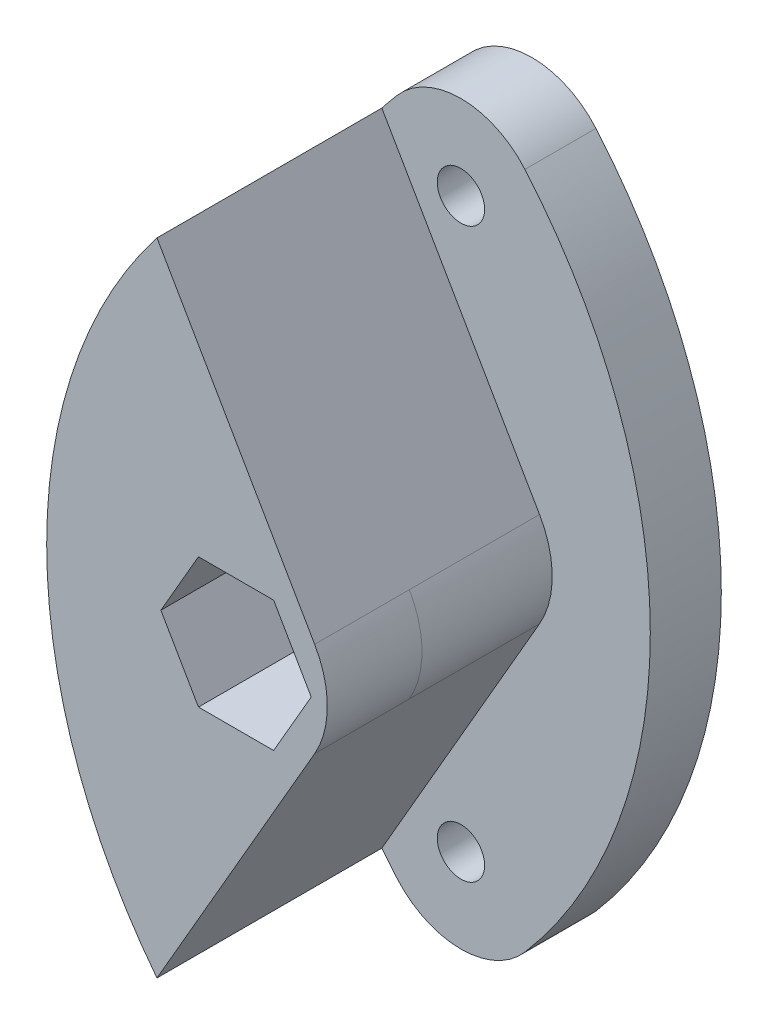
from build123d import *

# Parameters (mm, degrees)
AUFSATZ_LINEAR_AUSTRAGEN1_DEPTH                      = 5.5
VERRUNDUNG1_R                                        = 4
AUFSATZ_LINEAR_START                                 = -5.5
AUFSATZ_LINEAR_AUSTRAGEN4_DEPTH                      = 3
FORMSENKUNG_F_R_M3_SENKSCHRAUBE_MIT_INNE_D           = 2
FORMSENKUNG_F_R_M3_SENKSCHRAUBE_MIT_INNE_CSINK_D     = 4
FORMSENKUNG_F_R_M3_SENKSCHRAUBE_MIT_INNE_CSINK_ANGLE = 90
SCHNITT_LINEAR_AUSTRAGEN2_DEPTH                      = 1.5
AUFSATZ_LINEAR_AUSTRAGEN5_DEPTH                      = 4
STIRNSENKUNG_F_R_M3_ZYLINDERSCHRAUBE_MIT_D           = 3.2
STIRNSENKUNG_F_R_M3_ZYLINDERSCHRAUBE_MIT_CBORE_D     = 6.5
STIRNSENKUNG_F_R_M3_ZYLINDERSCHRAUBE_MIT_CBORE_DEPTH = 2
VERRUNDUNG2_R                                        = 4


with BuildPart() as part:
    # Skizze1 → Aufsatz-Linear austragen1 (new body)
    with BuildSketch(Plane.XY):
        with BuildLine():
            Line((18.475208614, 0), (10.658872913, 13.538290563))
            ThreePointArc((10.658872913, 13.538290563), (6, 0), (10.658872913, -13.538290563))
            Line((10.658872913, -13.538290563), (18.475208614, 0))
        make_face()
    extrude(amount=-AUFSATZ_LINEAR_AUSTRAGEN1_DEPTH)

    # Verrundung1
    verrundung1_edges = [part.edges().sort_by_distance(p)[0] for p in [
        (18.475208614, 0, -2.75),
    ]]
    fillet(verrundung1_edges, radius=VERRUNDUNG1_R)

    # Skizze1_4 → Aufsatz-Linear austragen4 (add)
    with BuildSketch(Plane.XY.offset(AUFSATZ_LINEAR_START)):
        with BuildLine():
            ThreePointArc((11.296354748, 14.317410216), (6, 0), (11.296354748, -14.317410216))
            ThreePointArc((11.296354748, -14.317410216), (14, -15.560911085), (16.703645252, -14.317410216))
            ThreePointArc((16.703645252, -14.317410216), (22, 0), (16.703645252, 14.317410216))
            ThreePointArc((16.703645252, 14.317410216), (14, 15.560911085), (11.296354748, 14.317410216))
        make_face()
    extrude(amount=-AUFSATZ_LINEAR_AUSTRAGEN4_DEPTH)

    # Formsenkung f_r M3 Senkschraube mit Inne (through all)
    with Locations(Plane(origin=(0, 0, -8.5), x_dir=(-1, 0, 0), z_dir=(0, 0, -1))):
        with Locations((-14, 12), (-14, -12)):
            CounterSinkHole(FORMSENKUNG_F_R_M3_SENKSCHRAUBE_MIT_INNE_D / 2, FORMSENKUNG_F_R_M3_SENKSCHRAUBE_MIT_INNE_CSINK_D / 2, counter_sink_angle=FORMSENKUNG_F_R_M3_SENKSCHRAUBE_MIT_INNE_CSINK_ANGLE)

    # Skizze1_5 → Schnitt-Linear austragen2 (cut)
    with BuildSketch(Plane.XY):
        Polygon((12.41228676, 2.75), (10.824573519, 0), (12.41228676, -2.75), (15.58771324, -2.75), (17.175426481, 0), (15.58771324, 2.75), align=None)
    extrude(amount=-SCHNITT_LINEAR_AUSTRAGEN2_DEPTH, mode=Mode.SUBTRACT)

    # Skizze1_6 → Aufsatz-Linear austragen5 (add)
    with BuildSketch(Plane.XY):
        with BuildLine():
            Line((18.475208614, 0), (10.658872913, 13.538290563))
            ThreePointArc((10.658872913, 13.538290563), (6, 0), (10.658872913, -13.538290563))
            Line((10.658872913, -13.538290563), (18.475208614, 0))
        make_face()
        Polygon((10.824573519, 0), (12.41228676, 2.75), (15.58771324, 2.75), (17.175426481, 0), (15.58771324, -2.75), (12.41228676, -2.75), align=None, mode=Mode.SUBTRACT)
    extrude(amount=AUFSATZ_LINEAR_AUSTRAGEN5_DEPTH)

    # Stirnsenkung f_r M3 Zylinderschraube mit (through all)
    with Locations(Plane(origin=(1.518806311, 4.633276693, -8.5), x_dir=(1, 0, 0), z_dir=(0, 0, -1))):
        with Locations((12.481193689, 4.633276693)):
            CounterBoreHole(STIRNSENKUNG_F_R_M3_ZYLINDERSCHRAUBE_MIT_D / 2, STIRNSENKUNG_F_R_M3_ZYLINDERSCHRAUBE_MIT_CBORE_D / 2, STIRNSENKUNG_F_R_M3_ZYLINDERSCHRAUBE_MIT_CBORE_DEPTH)

    # Verrundung2
    verrundung2_edges = [part.edges().sort_by_distance(p)[0] for p in [
        (18.475208614, 0, 2),
    ]]
    fillet(verrundung2_edges, radius=VERRUNDUNG2_R)


solid = part.part
